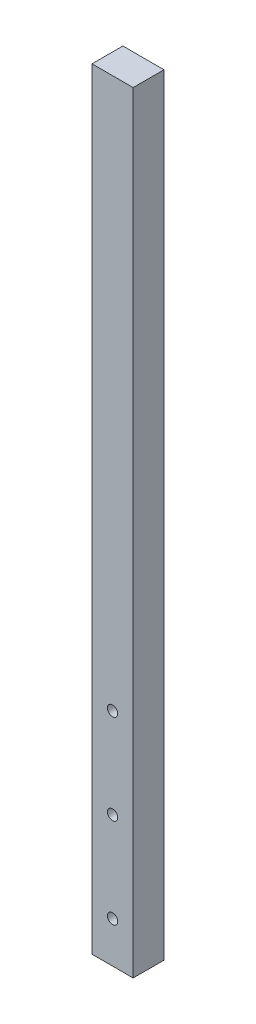
from build123d import *

# Parameters (mm, degrees)
MODEL_W             = 8
MODEL_H             = 150
MODEL_R             = 1
BOSS_EXTRUDE2_DEPTH = 6


with BuildPart() as part:
    # Model → Boss-Extrude2 (new body)
    with BuildSketch(Plane.XY):
        with Locations((51.821619875, 82.013307802)):
            Rectangle(MODEL_W, MODEL_H)
        with Locations((51.821619875, 15.013307802)):
            Circle(MODEL_R, mode=Mode.SUBTRACT)
        with Locations((51.821619875, 50.013307802)):
            Circle(MODEL_R, mode=Mode.SUBTRACT)
        with Locations((51.821619875, 32.513307802)):
            Circle(MODEL_R, mode=Mode.SUBTRACT)
    extrude(amount=BOSS_EXTRUDE2_DEPTH)


solid = part.part
